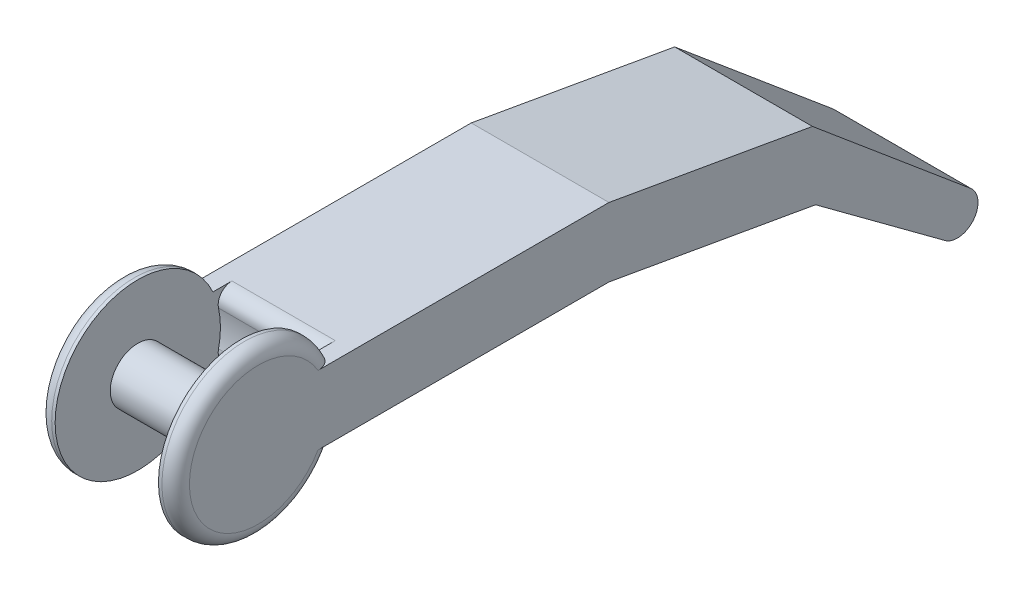
from build123d import *

# Parameters (mm, degrees)
BOSS_EXTRUDE1_DEPTH = 20
CUT_EXTRUDE1_START  = -2.5
SKETCH2_R           = 12
SKETCH2_R_2         = 4
CUT_EXTRUDE1_DEPTH  = 15
FILLET1_R           = 2
BOSS_EXTRUDE2_DEPTH = 20


with BuildPart() as part:
    # Sketch1 → Boss-Extrude1 (new body)
    with BuildSketch(Plane(origin=(0, 0, 0), x_dir=(0, 0, -1), z_dir=(1, 0, 0))):
        with BuildLine():
            Line((0, 0), (-40, 0))
            ThreePointArc((-40, 0), (-62.908712115, -5), (-40, -10))
            Line((-40, -10), (0, -10))
            Line((0, -10), (0, 0))
        make_face()
    extrude(amount=BOSS_EXTRUDE1_DEPTH)

    # Sketch2 → Cut-Extrude1 (cut)
    with BuildSketch(Plane(origin=(20, 0, 0), x_dir=(0, 0, -1), z_dir=(1, 0, 0)).offset(CUT_EXTRUDE1_START)):
        with Locations((-50.908712115, -5)):
            Circle(SKETCH2_R)
        with Locations((-50.908712115, -5)):
            Circle(SKETCH2_R_2, mode=Mode.SUBTRACT)
    extrude(amount=-CUT_EXTRUDE1_DEPTH, mode=Mode.SUBTRACT)

    # Fillet1
    fillet1_edges = [part.edges().sort_by_distance(p)[0] for p in [
        (0, -5, 62.908712115),
        (20, -5, 62.908712115),
        (10, -10, 40),
        (10, 0, 40),
    ]]
    fillet(fillet1_edges, radius=FILLET1_R)

    # Sketch3 → Boss-Extrude2 (add)
    with BuildSketch(Plane(origin=(20, 0, 0), x_dir=(0, 0, -1), z_dir=(1, 0, 0))):
        with BuildLine():
            Line((0, 0), (29.54423259, -5.20944533))
            Line((29.54423259, -5.20944533), (52.525565884, -24.493073621))
            ThreePointArc((52.525565884, -24.493073621), (52.883353103, -28.709461138), (48.668892888, -29.089277519))
            Line((48.668892888, -29.089277519), (30, -15.289809421))
            Line((30, -15.289809421), (0, -10))
            Line((0, -10), (0, 0))
        make_face()
    extrude(amount=-BOSS_EXTRUDE2_DEPTH)


solid = part.part
